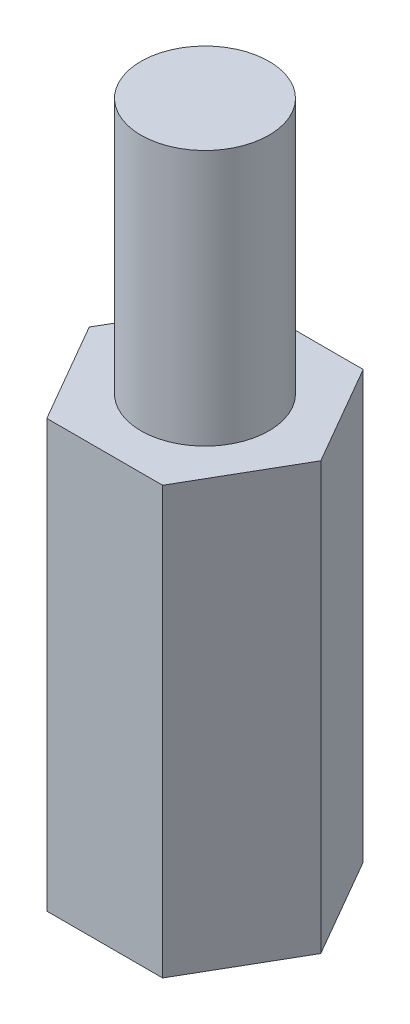
from build123d import *

# Parameters (mm, degrees)
BOSS_EXTRUDE1_DEPTH = 10
SKETCH2_R           = 1.5
BOSS_EXTRUDE2_DEPTH = 6
SKETCH3_R           = 1.25
CUT_EXTRUDE1_DEPTH  = 6


with BuildPart() as part:
    # Sketch1 → Boss-Extrude1 (new body)
    with BuildSketch(Plane(origin=(0, 0, 0), x_dir=(1, 0, 0), z_dir=(0, 1, 0))):
        Polygon((2.713546265, 0), (1.356773133, 2.35), (-1.356773133, 2.35), (-2.713546265, 0), (-1.356773133, -2.35), (1.356773133, -2.35), align=None)
    extrude(amount=BOSS_EXTRUDE1_DEPTH)

    # Sketch2 → Boss-Extrude2 (add)
    with BuildSketch(Plane(origin=(0, 10, 0), x_dir=(1, 0, 0), z_dir=(0, 1, 0))):
        Circle(SKETCH2_R)
    extrude(amount=BOSS_EXTRUDE2_DEPTH)

    # Sketch3 → Cut-Extrude1 (cut)
    with BuildSketch(Plane.XZ):
        Circle(SKETCH3_R)
    extrude(amount=-CUT_EXTRUDE1_DEPTH, mode=Mode.SUBTRACT)


solid = part.part
